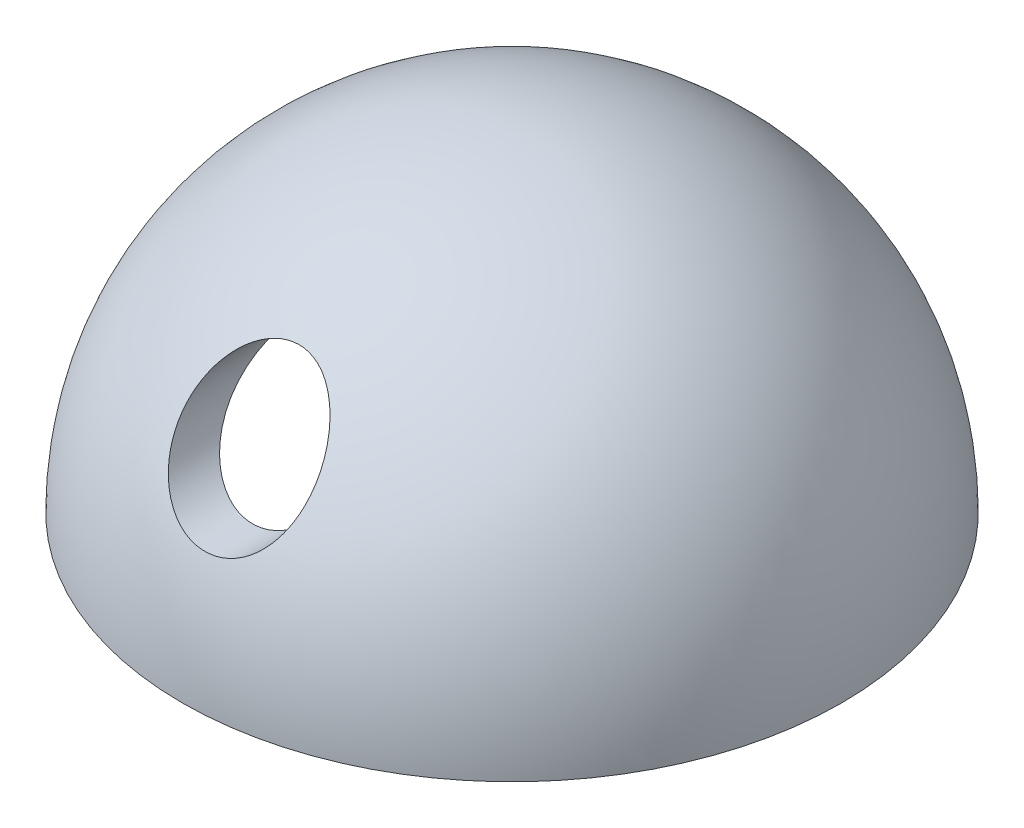
from build123d import *

# Parameters (mm, degrees)
VACIADO2_T            = -2
CROQUIS2_R            = 3
CORTAR_EXTRUIR1_DEPTH = 26.980762114


with BuildPart() as part:
    # Croquis1 → Revolución1 (revolve)
    with BuildSketch(Plane.XY):
        with BuildLine():
            Line((0, 0), (0, 15))
            ThreePointArc((0, 15), (-10.606601718, 10.606601718), (-15, 0))
            Line((-15, 0), (0, 0))
        make_face()
    revolve(axis=Axis((0, 0, 0), (0, 1, 0)))

    # Vaciado2
    vaciado2_openings = [part.faces().sort_by_distance(p)[0] for p in [
        (0, 0, 0),
    ]]
    offset(amount=VACIADO2_T, openings=vaciado2_openings, kind=Kind.INTERSECTION)

    # Croquis2 → Cortar-Extruir1 (cut, through all)
    with BuildSketch(Plane.XY):
        with Locations(Location((0, 8.456456299, 0), (0, 0, 111.940512479))):
            Circle(CROQUIS2_R)
    extrude(amount=CORTAR_EXTRUIR1_DEPTH, mode=Mode.SUBTRACT)


solid = part.part
